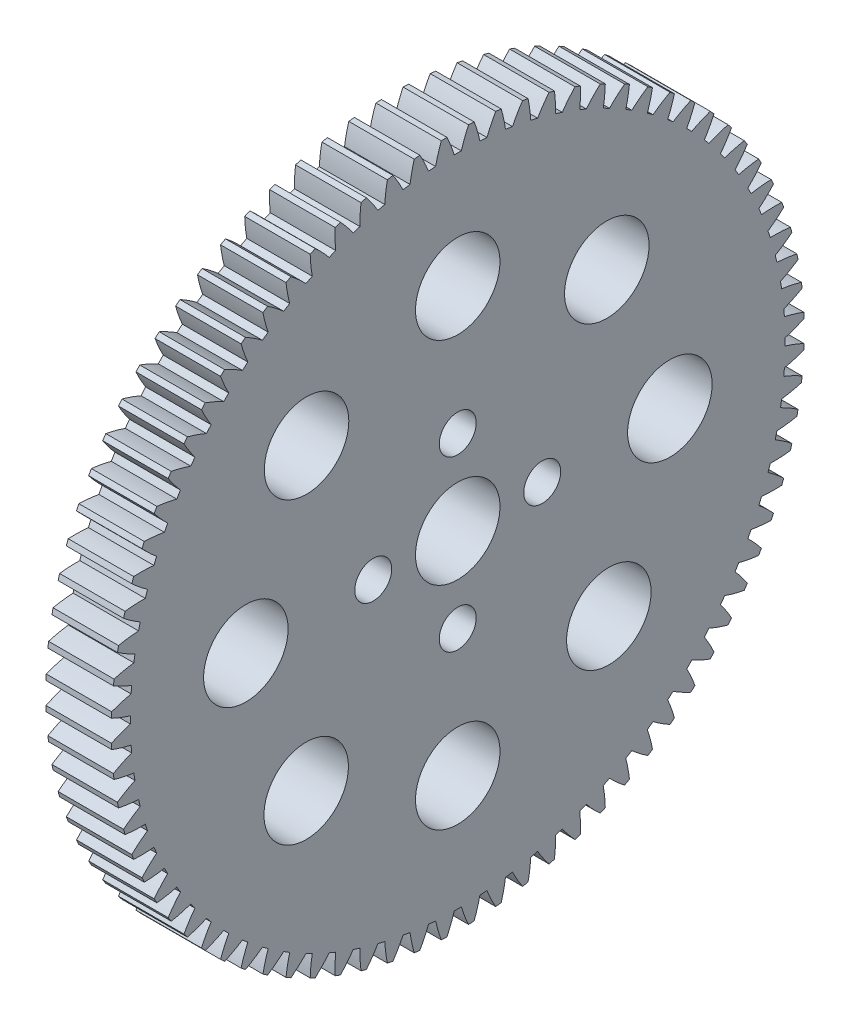
from build123d import *

# Parameters (mm, degrees)
BASPROSKE_W        = 6.2
BASPROSKE_H        = 32.8
TOOTHCUT_DEPTH     = 47.798717931
TEETHCUTS_COUNT    = 80
TEETHCUTS_ANGLE    = 355.5
BORSKE_R           = 4
BORE_DEPTH         = 50.0000508
SKETCH1_R          = 4
SKETCH1_R_2        = 1.75
CUT_EXTRUDE1_DEPTH = 47.776337838


with BuildPart() as part:
    # BasProSke → Base-Revolve (revolve)
    with BuildSketch(Plane(origin=(0, 0, 0), x_dir=(1, 0, 0), z_dir=(0, 1, 0)), mode=Mode.PRIVATE) as base_revolve_sk:
        with Locations((3.1, 16.4)):
            Rectangle(BASPROSKE_W, BASPROSKE_H)
    revolve(base_revolve_sk.sketch.rotate(Axis((-10, 0, 0), (1, 0, 0)), 180), axis=Axis((-10, 0, 0), (1, 0, 0)))

    # TooCutSke → ToothCut (cut, through all)
    with BuildSketch(Plane(origin=(0, 0, 0), x_dir=(0, 0, -1), z_dir=(1, 0, 0))):
        with BuildLine():
            ThreePointArc((0.335706178, 30.997182168), (0, 30.999), (-0.335706178, 30.997182168))
            ThreePointArc((-0.335706178, 30.997182168), (-0.651023397, 31.916413715), (-1.035171918, 32.809073505))
            ThreePointArc((-1.035171918, 32.809073505), (0, 32.8254), (1.035171918, 32.809073505))
            ThreePointArc((1.035171918, 32.809073505), (0.651023397, 31.916413715), (0.335706178, 30.997182168))
        make_face()
    toothcut = extrude(amount=TOOTHCUT_DEPTH, mode=Mode.SUBTRACT)

    # TeethCuts: ToothCut ×80 about axis
    teethcuts_axis = Axis((-10, 0, 0), (1, 0, 0))
    for i in range(1, TEETHCUTS_COUNT):
        add(toothcut.rotate(teethcuts_axis, i * TEETHCUTS_ANGLE / (TEETHCUTS_COUNT - 1)), mode=Mode.SUBTRACT)

    # BorSke → Bore (cut, symmetric)
    with BuildSketch(Plane(origin=(0, 0, 0), x_dir=(0, 0, -1), z_dir=(1, 0, 0))):
        with Locations(Location((0, 0, 0), (0, 0, 180))):
            Circle(BORSKE_R)
    extrude(amount=BORE_DEPTH, both=True, mode=Mode.SUBTRACT)

    # Sketch1 → Cut-Extrude1 (cut, through all)
    with BuildSketch(Plane(origin=(6.2, 0, 0), x_dir=(0, 0, -1), z_dir=(1, 0, 0))):
        with Locations((0, 20.084034083)):
            Circle(SKETCH1_R)
        with Locations((0, -20.063257749)):
            Circle(SKETCH1_R)
        with Locations((20.084034083, 0)):
            Circle(SKETCH1_R)
        with Locations((-20.063257749, 0)):
            Circle(SKETCH1_R)
        with Locations((14.112602443, 14.36634376)):
            Circle(SKETCH1_R)
        with Locations((14.306921905, -14.14202094)):
            Circle(SKETCH1_R)
        with Locations((-14.348299993, -14.135100494)):
            Circle(SKETCH1_R)
        with Locations((-14.315040904, 14.159703758)):
            Circle(SKETCH1_R)
        with Locations((0, 8)):
            Circle(SKETCH1_R_2)
        with Locations((0, -8)):
            Circle(SKETCH1_R_2)
        with Locations((8, 0)):
            Circle(SKETCH1_R_2)
        with Locations((-8, 0)):
            Circle(SKETCH1_R_2)
    extrude(amount=-CUT_EXTRUDE1_DEPTH, mode=Mode.SUBTRACT)


solid = part.part
